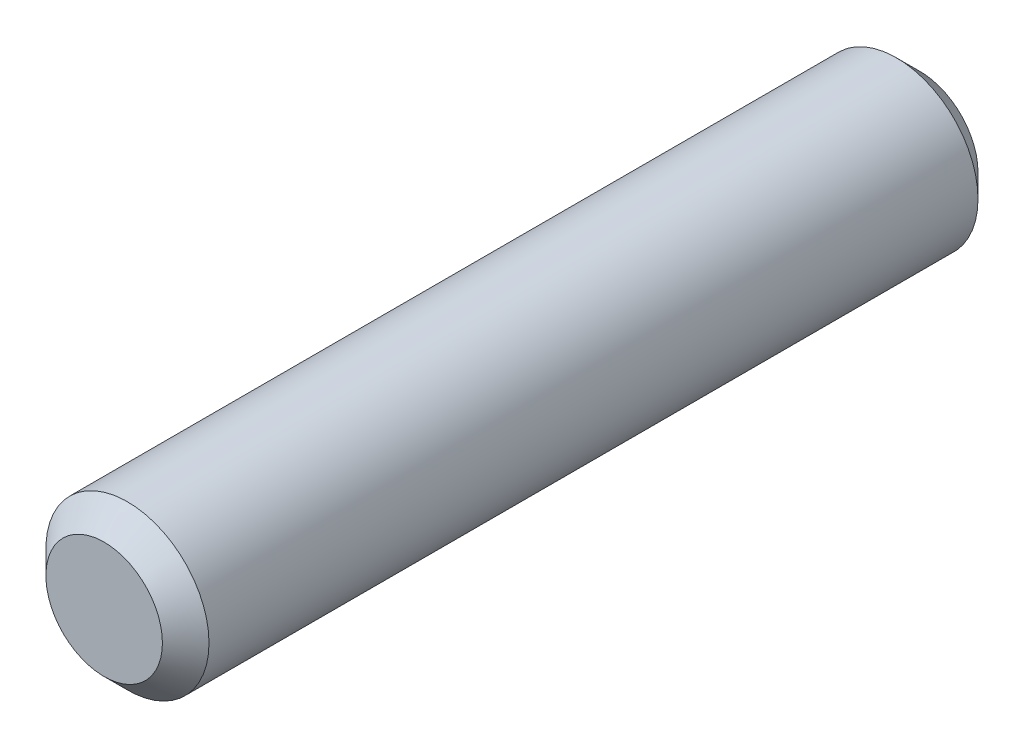
from build123d import *

# Parameters (mm, degrees)
SKETCH2_R           = 7
BOSS_EXTRUDE1_DEPTH = 35
CHAMFER1_SIZE       = 2
CHAMFER2_SIZE       = 2


with BuildPart() as part:
    # Sketch2 → Boss-Extrude1 (new body, symmetric)
    with BuildSketch(Plane.XY):
        Circle(SKETCH2_R)
    extrude(amount=BOSS_EXTRUDE1_DEPTH, both=True)

    # Chamfer1
    chamfer1_edges = [part.edges().sort_by_distance(p)[0] for p in [
        (-7, 0, -35),
    ]]
    chamfer(chamfer1_edges, length=CHAMFER1_SIZE)

    # Chamfer2
    chamfer2_edges = [part.edges().sort_by_distance(p)[0] for p in [
        (-7, 0, 35),
    ]]
    chamfer(chamfer2_edges, length=CHAMFER2_SIZE)


solid = part.part
